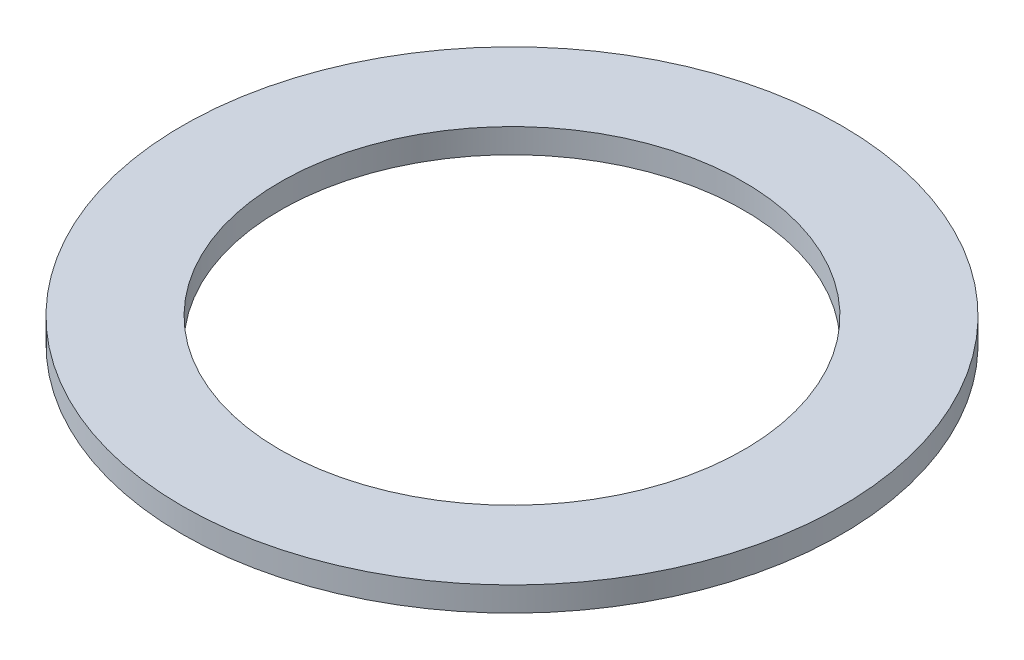
from build123d import *

# Parameters (mm, degrees)
SKETCH1_R          = 20.574
SKETCH1_R_2        = 14.478
BASE_EXTRUDE_DEPTH = 1.524


with BuildPart() as part:
    # Sketch1 → Base-Extrude (new body)
    with BuildSketch(Plane(origin=(0, 0, 0), x_dir=(1, 0, 0), z_dir=(0, 1, 0))):
        Circle(SKETCH1_R)
        Circle(SKETCH1_R_2, mode=Mode.SUBTRACT)
    extrude(amount=BASE_EXTRUDE_DEPTH)


solid = part.part
